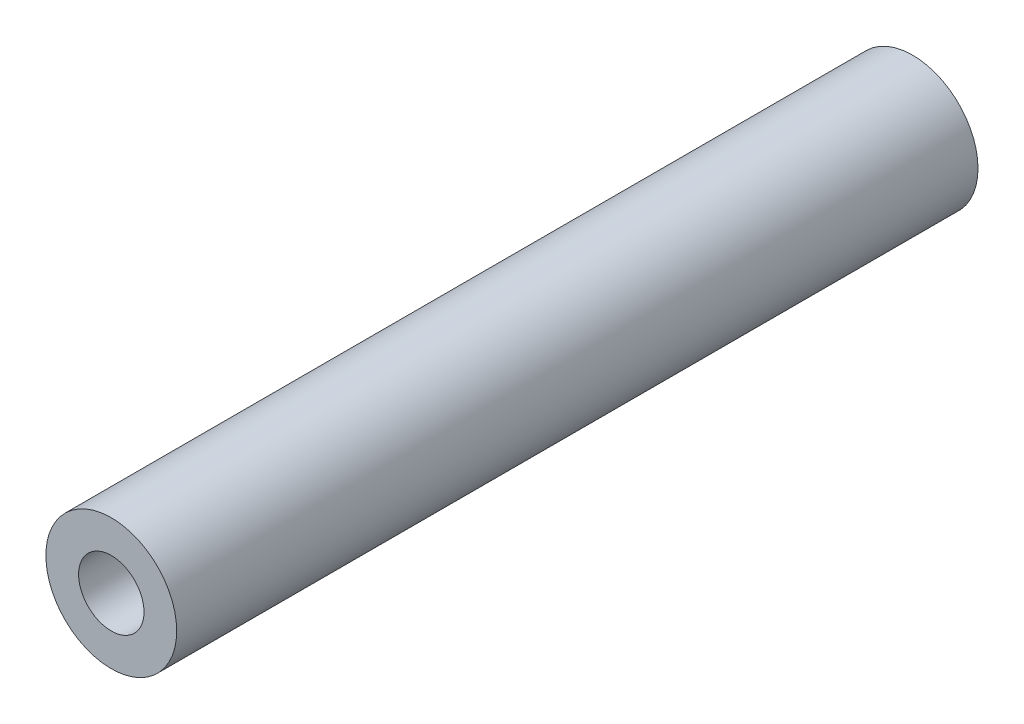
from build123d import *

# Parameters (mm, degrees)
ESQUISSE1_R      = 4
EXTRUSION2_DEPTH = 49
ESQUISSE2_R      = 2
EXTRUSION3_DEPTH = 10
ESQUISSE3_R      = 2
EXTRUSION4_DEPTH = 10


with BuildPart() as part:
    # Esquisse1 → Extrusion2 (new body)
    with BuildSketch(Plane.XY):
        Circle(ESQUISSE1_R)
    extrude(amount=EXTRUSION2_DEPTH)

    # Esquisse2 → Extrusion3 (cut)
    with BuildSketch(Plane.XY.offset(49)):
        Circle(ESQUISSE2_R)
    extrude(amount=-EXTRUSION3_DEPTH, mode=Mode.SUBTRACT)

    # Esquisse3 → Extrusion4 (cut)
    with BuildSketch(Plane(origin=(0, 0, 0), x_dir=(-1, 0, 0), z_dir=(0, 0, -1))):
        Circle(ESQUISSE3_R)
    extrude(amount=-EXTRUSION4_DEPTH, mode=Mode.SUBTRACT)


solid = part.part
